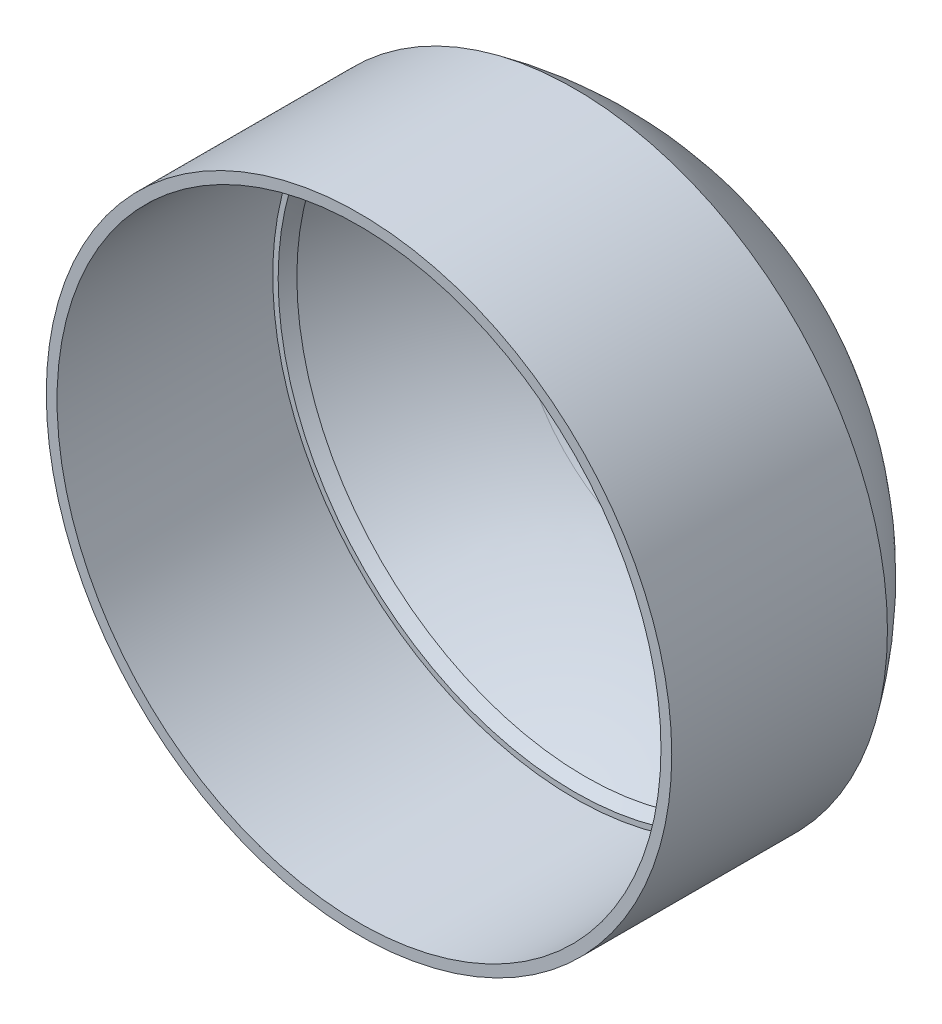
from build123d import *

# Parameters (mm, degrees)
SKETCH1_R           = 29
SKETCH1_R_2         = 28
EXTRUDE_THIN1_DEPTH = 10
SKETCH16_R          = 1.5
CUT_EXTRUDE2_DEPTH  = 26.001091713
SKETCH6_R           = 1.5
CUT_EXTRUDE1_DEPTH  = 1


with BuildPart() as part:
    # Sketch1 → Extrude-Thin1 (new body, symmetric)
    with BuildSketch(Plane.XY):
        Circle(SKETCH1_R)
        Circle(SKETCH1_R_2, mode=Mode.SUBTRACT)
    extrude(amount=EXTRUDE_THIN1_DEPTH, both=True)

    # Sketch5 → Revolve-Thin4 (revolve)
    with BuildSketch(Plane(origin=(0, 0, 0), x_dir=(0, 0, -1), z_dir=(1, 0, 0))):
        with BuildLine():
            Line((10, 29), (10, 0))
            Line((10, 0), (25, 0))
            ThreePointArc((25, 0), (21.088709123, 16.356228857), (10, 29))
        make_face()
        with BuildLine():
            Line((11, 27.016767879), (11, 1))
            Line((11, 1), (23.993391354, 1))
            ThreePointArc((23.993391354, 1), (20.418624313, 15.467664449), (11, 27.016767879))
        make_face(mode=Mode.SUBTRACT)
    revolve(axis=Axis((0, 0, 0), (0, 0, -1)))

    # Sketch7 → Cut-Revolve1 (revolve, cut)
    with BuildSketch(Plane(origin=(0, 0, 0), x_dir=(0, 0, -1), z_dir=(1, 0, 0))):
        with BuildLine():
            Line((10, 0), (24, 0))
            ThreePointArc((24, 0), (20.411655154, 15.485438383), (10, 27.496785417))
            Line((10, 27.496785417), (10, 0))
        make_face()
    revolve(axis=Axis((0, 0, -10), (0, 0, -1)), mode=Mode.SUBTRACT)

    # Sketch16 → Cut-Extrude2 (cut, through all)
    with BuildSketch(Plane.XY):
        Circle(SKETCH16_R)
    extrude(amount=-CUT_EXTRUDE2_DEPTH, mode=Mode.SUBTRACT)

    # Sketch6 → Cut-Extrude1 (cut)
    with BuildSketch(Plane.XY.offset(-10)):
        Circle(SKETCH6_R)
    extrude(amount=-CUT_EXTRUDE1_DEPTH, mode=Mode.SUBTRACT)


solid = part.part
